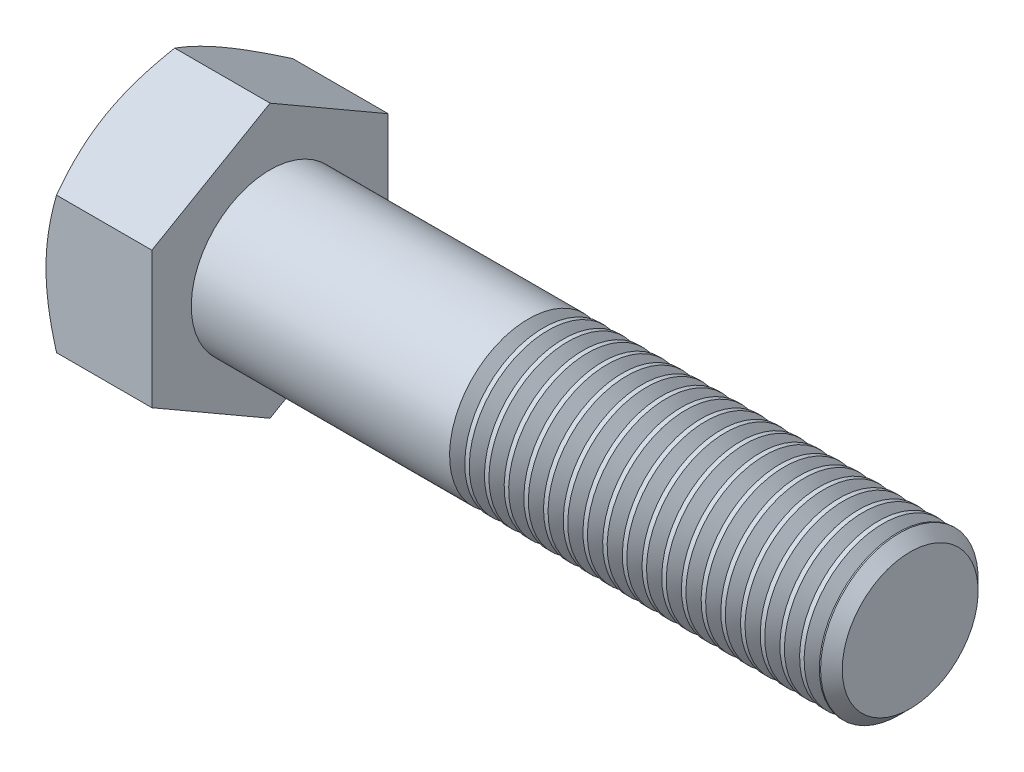
from build123d import *

# Parameters (mm, degrees)
BASEHEAD_DEPTH  = 10.75
THDSCHPAT_COUNT = 19
THDSCHPAT_PITCH = 2


with BuildPart() as part:
    # Sketch1 → BaseHead (new body)
    with BuildSketch(Plane(origin=(0, 0, 0), x_dir=(0, 0, -1), z_dir=(1, 0, 0))):
        Polygon((12, 6.92820323), (12, -6.92820323), (0, -13.856406461), (-12, -6.92820323), (-12, 6.92820323), (0, 13.856406461), align=None)
    extrude(amount=BASEHEAD_DEPTH)

    # BodySke → BaseBody (revolve)
    with BuildSketch(Plane.XY):
        Polygon((0, 0), (75.75, 0), (75.75, 6.8985), (74.6485, 8), (0, 8), align=None)
    revolve(axis=Axis((0, 0, 0), (1, 0, 0)))

    # Sketch3 → HeadChamfer (revolve, cut)
    with BuildSketch(Plane.XY):
        Polygon((0, 12), (3.958548116, 18.856406461), (3.958548116, 23.856406461), (-10, 23.856406461), (-10, 12), align=None)
    revolve(axis=Axis((0, 0, 0), (1, 0, 0)), mode=Mode.SUBTRACT)

    # ThdSchSke → ThreadSchematic (revolve, cut)
    with BuildSketch(Plane.XY):
        Polygon((37.75, -6.8985), (36.978721397, -8), (36.978721397, -10), (38.521278603, -10), (38.521278603, -8), align=None)
    threadschematic = revolve(axis=Axis((-3.175, 0, 0), (1, 0, 0)), mode=Mode.SUBTRACT)

    # ThdSchPat: ThreadSchematic ×19
    with Locations(*[(i * THDSCHPAT_PITCH, 0, 0) for i in range(1, THDSCHPAT_COUNT)]):
        add(threadschematic, mode=Mode.SUBTRACT)


solid = part.part
